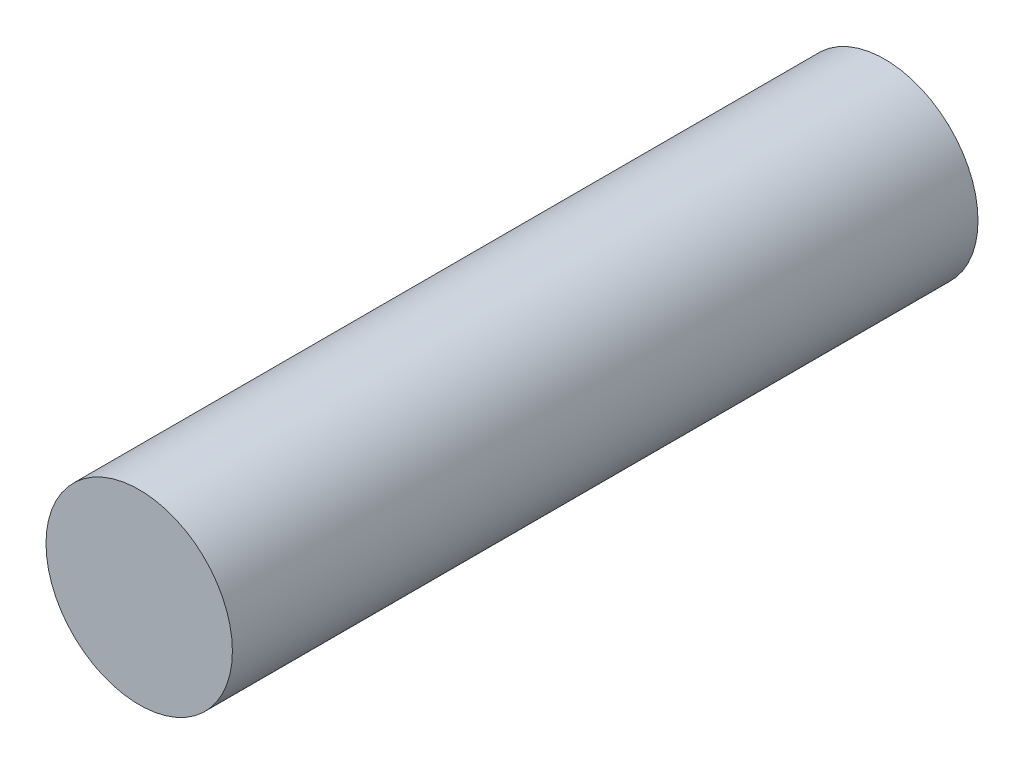
from build123d import *

# Parameters (mm, degrees)
SKETCH1_R           = 1.5
BOSS_EXTRUDE1_DEPTH = 12


with BuildPart() as part:
    # Sketch1 → Boss-Extrude1 (new body)
    with BuildSketch(Plane.XY):
        Circle(SKETCH1_R)
    extrude(amount=BOSS_EXTRUDE1_DEPTH)


solid = part.part
